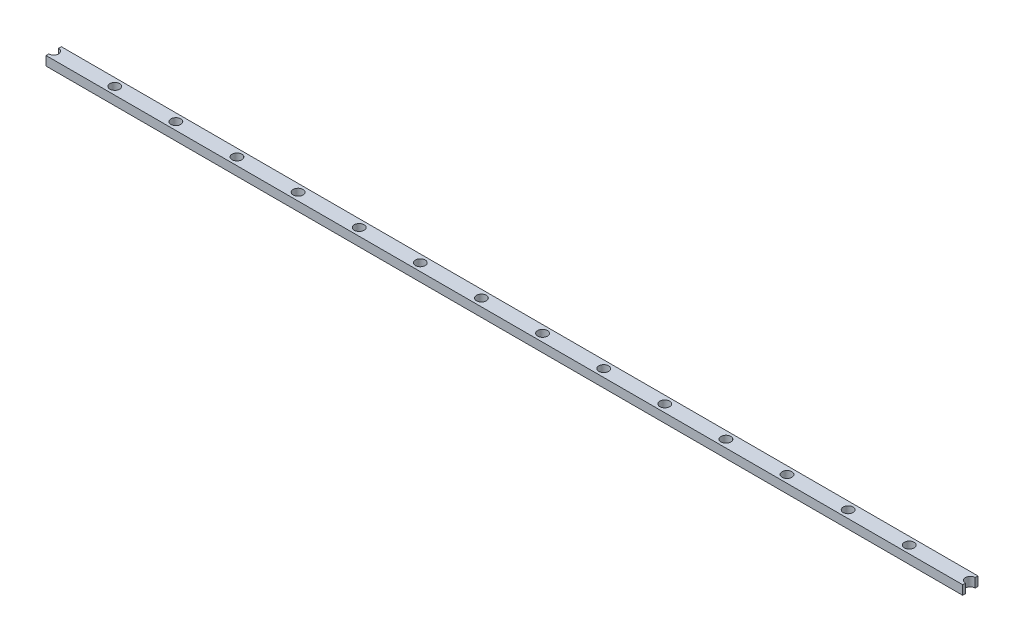
from build123d import *

# Parameters (mm, degrees)
SKETCH1_W           = 300
SKETCH1_H           = 5
BOSS_EXTRUDE1_DEPTH = 3
SKETCH2_R           = 1.6
CUT_EXTRUDE1_DEPTH  = 3


with BuildPart() as part:
    # Sketch1 → Boss-Extrude1 (new body)
    with BuildSketch(Plane(origin=(0, 0, 0), x_dir=(1, 0, 0), z_dir=(0, 1, 0))):
        with Locations((150, -2.5)):
            Rectangle(SKETCH1_W, SKETCH1_H)
    extrude(amount=BOSS_EXTRUDE1_DEPTH)

    # Sketch2 → Cut-Extrude1 (cut)
    with BuildSketch(Plane(origin=(0, 3, 0), x_dir=(1, 0, 0), z_dir=(0, 1, 0))):
        with Locations((0, -2.5)):
            Circle(SKETCH2_R)
        with Locations((20, -2.5)):
            Circle(SKETCH2_R)
        with Locations((40, -2.5)):
            Circle(SKETCH2_R)
        with Locations((60, -2.5)):
            Circle(SKETCH2_R)
        with Locations((80, -2.5)):
            Circle(SKETCH2_R)
        with Locations((100, -2.5)):
            Circle(SKETCH2_R)
        with Locations((120, -2.5)):
            Circle(SKETCH2_R)
        with Locations((140, -2.5)):
            Circle(SKETCH2_R)
        with Locations((160, -2.5)):
            Circle(SKETCH2_R)
        with Locations((180, -2.5)):
            Circle(SKETCH2_R)
        with Locations((200, -2.5)):
            Circle(SKETCH2_R)
        with Locations((220, -2.5)):
            Circle(SKETCH2_R)
        with Locations((240, -2.5)):
            Circle(SKETCH2_R)
        with Locations((260, -2.5)):
            Circle(SKETCH2_R)
        with Locations((280, -2.5)):
            Circle(SKETCH2_R)
        with Locations((300, -2.5)):
            Circle(SKETCH2_R)
        with Locations((320, -2.5)):
            Circle(SKETCH2_R)
        with Locations((340, -2.5)):
            Circle(SKETCH2_R)
        with Locations((360, -2.5)):
            Circle(SKETCH2_R)
        with Locations((380, -2.5)):
            Circle(SKETCH2_R)
        with Locations((400, -2.5)):
            Circle(SKETCH2_R)
        with Locations((420, -2.5)):
            Circle(SKETCH2_R)
        with Locations((440, -2.5)):
            Circle(SKETCH2_R)
        with Locations((460, -2.5)):
            Circle(SKETCH2_R)
        with Locations((480, -2.5)):
            Circle(SKETCH2_R)
        with Locations((500, -2.5)):
            Circle(SKETCH2_R)
        with Locations((520, -2.5)):
            Circle(SKETCH2_R)
        with Locations((540, -2.5)):
            Circle(SKETCH2_R)
        with Locations((560, -2.5)):
            Circle(SKETCH2_R)
        with Locations((580, -2.5)):
            Circle(SKETCH2_R)
        with Locations((600, -2.5)):
            Circle(SKETCH2_R)
        with Locations((620, -2.5)):
            Circle(SKETCH2_R)
        with Locations((640, -2.5)):
            Circle(SKETCH2_R)
        with Locations((660, -2.5)):
            Circle(SKETCH2_R)
        with Locations((680, -2.5)):
            Circle(SKETCH2_R)
        with Locations((700, -2.5)):
            Circle(SKETCH2_R)
        with Locations((720, -2.5)):
            Circle(SKETCH2_R)
        with Locations((740, -2.5)):
            Circle(SKETCH2_R)
        with Locations((760, -2.5)):
            Circle(SKETCH2_R)
        with Locations((780, -2.5)):
            Circle(SKETCH2_R)
        with Locations((800, -2.5)):
            Circle(SKETCH2_R)
        with Locations((820, -2.5)):
            Circle(SKETCH2_R)
        with Locations((840, -2.5)):
            Circle(SKETCH2_R)
        with Locations((860, -2.5)):
            Circle(SKETCH2_R)
        with Locations((880, -2.5)):
            Circle(SKETCH2_R)
        with Locations((900, -2.5)):
            Circle(SKETCH2_R)
        with Locations((920, -2.5)):
            Circle(SKETCH2_R)
        with Locations((940, -2.5)):
            Circle(SKETCH2_R)
        with Locations((960, -2.5)):
            Circle(SKETCH2_R)
        with Locations((980, -2.5)):
            Circle(SKETCH2_R)
        with Locations((1000, -2.5)):
            Circle(SKETCH2_R)
        with Locations((1020, -2.5)):
            Circle(SKETCH2_R)
        with Locations((1040, -2.5)):
            Circle(SKETCH2_R)
        with Locations((1060, -2.5)):
            Circle(SKETCH2_R)
        with Locations((1080, -2.5)):
            Circle(SKETCH2_R)
        with Locations((1100, -2.5)):
            Circle(SKETCH2_R)
        with Locations((1120, -2.5)):
            Circle(SKETCH2_R)
        with Locations((1140, -2.5)):
            Circle(SKETCH2_R)
        with Locations((1160, -2.5)):
            Circle(SKETCH2_R)
        with Locations((1180, -2.5)):
            Circle(SKETCH2_R)
        with Locations((1200, -2.5)):
            Circle(SKETCH2_R)
        with Locations((1220, -2.5)):
            Circle(SKETCH2_R)
        with Locations((1240, -2.5)):
            Circle(SKETCH2_R)
        with Locations((1260, -2.5)):
            Circle(SKETCH2_R)
        with Locations((1280, -2.5)):
            Circle(SKETCH2_R)
        with Locations((1300, -2.5)):
            Circle(SKETCH2_R)
        with Locations((1320, -2.5)):
            Circle(SKETCH2_R)
        with Locations((1340, -2.5)):
            Circle(SKETCH2_R)
        with Locations((1360, -2.5)):
            Circle(SKETCH2_R)
        with Locations((1380, -2.5)):
            Circle(SKETCH2_R)
        with Locations((1400, -2.5)):
            Circle(SKETCH2_R)
        with Locations((1420, -2.5)):
            Circle(SKETCH2_R)
        with Locations((1440, -2.5)):
            Circle(SKETCH2_R)
        with Locations((1460, -2.5)):
            Circle(SKETCH2_R)
        with Locations((1480, -2.5)):
            Circle(SKETCH2_R)
        with Locations((1500, -2.5)):
            Circle(SKETCH2_R)
        with Locations((1520, -2.5)):
            Circle(SKETCH2_R)
        with Locations((1540, -2.5)):
            Circle(SKETCH2_R)
        with Locations((1560, -2.5)):
            Circle(SKETCH2_R)
        with Locations((1580, -2.5)):
            Circle(SKETCH2_R)
        with Locations((1600, -2.5)):
            Circle(SKETCH2_R)
        with Locations((1620, -2.5)):
            Circle(SKETCH2_R)
        with Locations((1640, -2.5)):
            Circle(SKETCH2_R)
        with Locations((1660, -2.5)):
            Circle(SKETCH2_R)
        with Locations((1680, -2.5)):
            Circle(SKETCH2_R)
        with Locations((1700, -2.5)):
            Circle(SKETCH2_R)
        with Locations((1720, -2.5)):
            Circle(SKETCH2_R)
        with Locations((1740, -2.5)):
            Circle(SKETCH2_R)
        with Locations((1760, -2.5)):
            Circle(SKETCH2_R)
        with Locations((1780, -2.5)):
            Circle(SKETCH2_R)
        with Locations((1800, -2.5)):
            Circle(SKETCH2_R)
        with Locations((1820, -2.5)):
            Circle(SKETCH2_R)
        with Locations((1840, -2.5)):
            Circle(SKETCH2_R)
        with Locations((1860, -2.5)):
            Circle(SKETCH2_R)
        with Locations((1880, -2.5)):
            Circle(SKETCH2_R)
        with Locations((1900, -2.5)):
            Circle(SKETCH2_R)
        with Locations((1920, -2.5)):
            Circle(SKETCH2_R)
        with Locations((1940, -2.5)):
            Circle(SKETCH2_R)
        with Locations((1960, -2.5)):
            Circle(SKETCH2_R)
        with Locations((1980, -2.5)):
            Circle(SKETCH2_R)
    extrude(amount=-CUT_EXTRUDE1_DEPTH, mode=Mode.SUBTRACT)


solid = part.part
